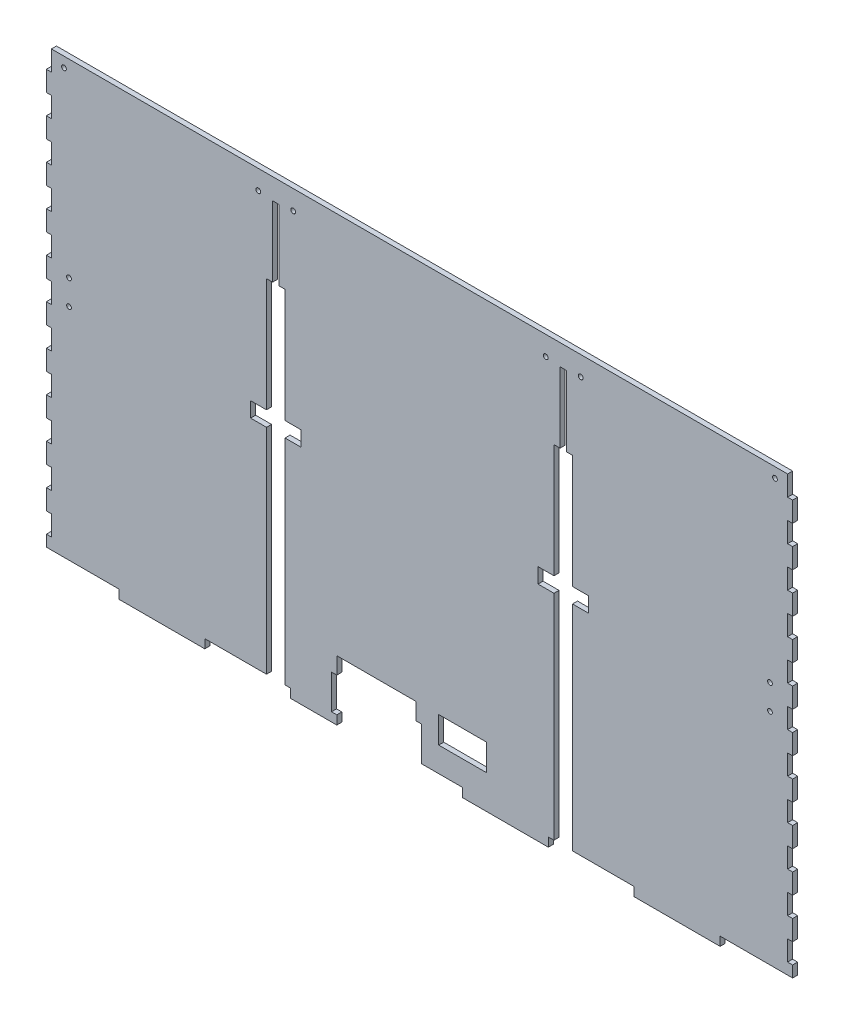
from build123d import *

# Parameters (mm, degrees)
SKETCH1_W                    = 3.175
SKETCH1_H                    = 12.7
MAIN_EXTRUDE_DEPTH           = 3.175
SKETCH8_R                    = 1.5
SKETCH8_W                    = 3.175
SKETCH8_H                    = 31.877
MOUNT_HOLES_DEPTH            = 430.752406189
DOOR_SLOTS_DEPTH             = 430.752406189
SKETCH4_W                    = 30.099999998
SKETCH4_H                    = 16.699
TROUGH_AND_LEVER_HOLES_DEPTH = 430.752406189
SKETCH10_R                   = 1.5
DOOR_GUIDE_MOUNT_HOLES_DEPTH = 430.752406189
SKETCH12_R                   = 1.5
EXTENSION_CLIP_HOLES_DEPTH   = 430.752406189
EXTENSION_CENTER_CUT_DEPTH   = 430.752406189


with BuildPart() as part:
    # Sketch1 → Main Extrude (new body)
    with BuildSketch(Plane.XY):
        Polygon((-381, 139.7), (-406.4, 139.7), (-406.4, -139.7), (-352.213333333, -139.7), (-352.213333333, -134.112), (-298.026666667, -134.112), (-298.026666667, -139.7), (-243.84, -139.7), (-243.84, -134.112), (-189.653333333, -134.112), (-189.653333333, -139.7), (-135.466666667, -139.7), (-135.466666667, -134.112), (-81.28, -134.112), (-81.28, -139.7), (-27.093333333, -139.7), (-27.093333333, -134.112), (27.093333333, -134.112), (27.093333333, -139.7), (81.28, -139.7), (81.28, -134.112), (135.466666667, -134.112), (135.466666667, -139.7), (189.653333333, -139.7), (189.653333333, -134.112), (243.84, -134.112), (243.84, -139.7), (298.026666667, -139.7), (298.026666667, -134.112), (352.213333333, -134.112), (352.213333333, -139.7), (406.4, -139.7), (406.4, 139.7), (381, 139.7), (381, 127), (377.825, 127), (377.825, 139.7), (-377.825, 139.7), (-377.825, 127), (-381, 127), align=None)
        with Locations((-379.4125, 107.95)):
            Rectangle(SKETCH1_W, SKETCH1_H, mode=Mode.SUBTRACT)
        with Locations((-379.4125, 82.55)):
            Rectangle(SKETCH1_W, SKETCH1_H, mode=Mode.SUBTRACT)
        with Locations((-379.4125, 57.15)):
            Rectangle(SKETCH1_W, SKETCH1_H, mode=Mode.SUBTRACT)
        with Locations((-379.4125, 31.75)):
            Rectangle(SKETCH1_W, SKETCH1_H, mode=Mode.SUBTRACT)
        with Locations((-379.4125, 6.35)):
            Rectangle(SKETCH1_W, SKETCH1_H, mode=Mode.SUBTRACT)
        with Locations((-379.4125, -19.05)):
            Rectangle(SKETCH1_W, SKETCH1_H, mode=Mode.SUBTRACT)
        with Locations((-379.4125, -44.45)):
            Rectangle(SKETCH1_W, SKETCH1_H, mode=Mode.SUBTRACT)
        with Locations((-379.4125, -69.85)):
            Rectangle(SKETCH1_W, SKETCH1_H, mode=Mode.SUBTRACT)
        with Locations((-379.4125, -95.25)):
            Rectangle(SKETCH1_W, SKETCH1_H, mode=Mode.SUBTRACT)
        with Locations((-379.4125, -120.65)):
            Rectangle(SKETCH1_W, SKETCH1_H, mode=Mode.SUBTRACT)
        with Locations((379.4125, 107.95)):
            Rectangle(SKETCH1_W, SKETCH1_H, mode=Mode.SUBTRACT)
        with Locations((379.4125, 82.55)):
            Rectangle(SKETCH1_W, SKETCH1_H, mode=Mode.SUBTRACT)
        with Locations((379.4125, 57.15)):
            Rectangle(SKETCH1_W, SKETCH1_H, mode=Mode.SUBTRACT)
        with Locations((379.4125, 31.75)):
            Rectangle(SKETCH1_W, SKETCH1_H, mode=Mode.SUBTRACT)
        with Locations((379.4125, 6.35)):
            Rectangle(SKETCH1_W, SKETCH1_H, mode=Mode.SUBTRACT)
        with Locations((379.4125, -19.05)):
            Rectangle(SKETCH1_W, SKETCH1_H, mode=Mode.SUBTRACT)
        with Locations((379.4125, -44.45)):
            Rectangle(SKETCH1_W, SKETCH1_H, mode=Mode.SUBTRACT)
        with Locations((379.4125, -69.85)):
            Rectangle(SKETCH1_W, SKETCH1_H, mode=Mode.SUBTRACT)
        with Locations((379.4125, -95.25)):
            Rectangle(SKETCH1_W, SKETCH1_H, mode=Mode.SUBTRACT)
        with Locations((379.4125, -120.65)):
            Rectangle(SKETCH1_W, SKETCH1_H, mode=Mode.SUBTRACT)
    extrude(amount=MAIN_EXTRUDE_DEPTH)

    # Sketch8 → Mount Holes (cut, through all)
    with BuildSketch(Plane.XY.offset(3.175)):
        with Locations((-393.7, -120.65)):
            Circle(SKETCH8_R)
        with Locations((393.7, -120.65)):
            Circle(SKETCH8_R)
        with Locations((-382.5875, 12.319)):
            Rectangle(SKETCH8_W, SKETCH8_H)
        with Locations((382.5875, 12.319)):
            Rectangle(SKETCH8_W, SKETCH8_H)
    extrude(amount=-MOUNT_HOLES_DEPTH, mode=Mode.SUBTRACT)

    # Sketch3 → Door Slots (cut, through all)
    with BuildSketch(Plane.XY.offset(3.175)):
        Polygon((-88.7095, 126.492), (-92.6465, 126.492), (-92.6465, 82.042), (-96.52, 82.042), (-96.52, 10.3505), (-106.553, 10.3505), (-106.553, 0.8255), (-96.52, 0.8255), (-96.52, -134.112), (-84.836, -134.112), (-84.836, 0.8255), (-74.803, 0.8255), (-74.803, 10.3505), (-84.836, 10.3505), (-84.836, 82.042), (-88.7095, 82.042), align=None)
        Polygon((92.6465, 126.492), (88.7095, 126.492), (88.7095, 82.042), (84.836, 82.042), (84.836, 10.3505), (74.803, 10.3505), (74.803, 0.8255), (84.836, 0.8255), (84.836, -134.112), (96.52, -134.112), (96.52, 0.8255), (106.553, 0.8255), (106.553, 10.3505), (96.52, 10.3505), (96.52, 82.042), (92.6465, 82.042), align=None)
    extrude(amount=-DOOR_SLOTS_DEPTH, mode=Mode.SUBTRACT)

    # Sketch4 → Trough and Lever Holes (cut, through all)
    with BuildSketch(Plane.XY):
        Polygon((-52.178, -112.40999997), (-55.48, -112.40999997), (-55.48, -134.112), (-52.178, -134.112), (-52.178, -139.7), (-2.178, -139.7), (-2.178, -134.112), (1.124, -134.112), (1.124, -112.40999997), (-2.178, -112.40999997), (-2.178, -101.792), (-52.178, -101.792), align=None)
        with Locations((27.178, -110.1415)):
            Rectangle(SKETCH4_W, SKETCH4_H)
    extrude(amount=TROUGH_AND_LEVER_HOLES_DEPTH, mode=Mode.SUBTRACT)

    # Sketch10 → Door Guide Mount Holes (cut, through all)
    with BuildSketch(Plane.XY.offset(3.175)):
        with Locations((-101.678, 127.492)):
            Circle(SKETCH10_R)
        with Locations((-79.678, 127.492)):
            Circle(SKETCH10_R)
        with Locations((79.678, 127.492)):
            Circle(SKETCH10_R)
        with Locations((101.678, 127.492)):
            Circle(SKETCH10_R)
    extrude(amount=-DOOR_GUIDE_MOUNT_HOLES_DEPTH, mode=Mode.SUBTRACT)

    # Sketch12 → Extension Clip Holes (cut, through all)
    with BuildSketch(Plane.XY.offset(3.175)):
        with Locations((-246.507, 20.193)):
            Circle(SKETCH12_R)
        with Locations((-246.507, 4.445)):
            Circle(SKETCH12_R)
        with Locations((-221.107, 4.445)):
            Circle(SKETCH12_R)
        with Locations((-221.107, 20.193)):
            Circle(SKETCH12_R)
        with Locations((-243.332, 133.35)):
            Circle(SKETCH12_R)
        with Locations((-224.282, 133.35)):
            Circle(SKETCH12_R)
        with Locations((224.282, 133.35)):
            Circle(SKETCH12_R)
        with Locations((243.332, 133.35)):
            Circle(SKETCH12_R)
        with Locations((221.107, 20.193)):
            Circle(SKETCH12_R)
        with Locations((221.107, 4.445)):
            Circle(SKETCH12_R)
        with Locations((246.507, 4.445)):
            Circle(SKETCH12_R)
        with Locations((246.507, 20.193)):
            Circle(SKETCH12_R)
    extrude(amount=-EXTENSION_CLIP_HOLES_DEPTH, mode=Mode.SUBTRACT)

    # Sketch11_3 → Extension Center Cut (cut, through all)
    with BuildSketch(Plane.XY.offset(3.175)):
        Polygon((-232.2195, 127), (-232.2195, 139.7), (-406.4, 139.7), (-406.4, -139.7), (-235.3945, -139.7), (-235.3945, -127), (-232.2195, -127), (-232.2195, -114.3), (-235.3945, -114.3), (-235.3945, -101.6), (-232.2195, -101.6), (-232.2195, -88.9), (-235.3945, -88.9), (-235.3945, -76.2), (-232.2195, -76.2), (-232.2195, -63.5), (-235.3945, -63.5), (-235.3945, -50.8), (-232.2195, -50.8), (-232.2195, -38.1), (-235.3945, -38.1), (-235.3945, -25.4), (-232.2195, -25.4), (-232.2195, -12.7), (-235.3945, -12.7), (-235.3945, 0), (-232.2195, 0), (-232.2195, 12.7), (-235.3945, 12.7), (-235.3945, 25.4), (-232.2195, 25.4), (-232.2195, 38.1), (-235.3945, 38.1), (-235.3945, 50.8), (-232.2195, 50.8), (-232.2195, 63.5), (-235.3945, 63.5), (-235.3945, 76.2), (-232.2195, 76.2), (-232.2195, 88.9), (-235.3945, 88.9), (-235.3945, 101.6), (-232.2195, 101.6), (-232.2195, 114.3), (-235.3945, 114.3), (-235.3945, 127), align=None)
        Polygon((406.4, 139.7), (232.2195, 139.7), (232.2195, 127), (235.3945, 127), (235.3945, 114.3), (232.2195, 114.3), (232.2195, 101.6), (235.3945, 101.6), (235.3945, 88.9), (232.2195, 88.9), (232.2195, 76.2), (235.3945, 76.2), (235.3945, 63.5), (232.2195, 63.5), (232.2195, 50.8), (235.3945, 50.8), (235.3945, 38.1), (232.2195, 38.1), (232.2195, 25.4), (235.3945, 25.4), (235.3945, 12.7), (232.2195, 12.7), (232.2195, 0), (235.3945, 0), (235.3945, -12.7), (232.2195, -12.7), (232.2195, -25.4), (235.3945, -25.4), (235.3945, -38.1), (232.2195, -38.1), (232.2195, -50.8), (235.3945, -50.8), (235.3945, -63.5), (232.2195, -63.5), (232.2195, -76.2), (235.3945, -76.2), (235.3945, -88.9), (232.2195, -88.9), (232.2195, -101.6), (235.3945, -101.6), (235.3945, -114.3), (232.2195, -114.3), (232.2195, -127), (235.3945, -127), (235.3945, -139.7), (406.4, -139.7), align=None)
    extrude(amount=-EXTENSION_CENTER_CUT_DEPTH, mode=Mode.SUBTRACT)


solid = part.part
